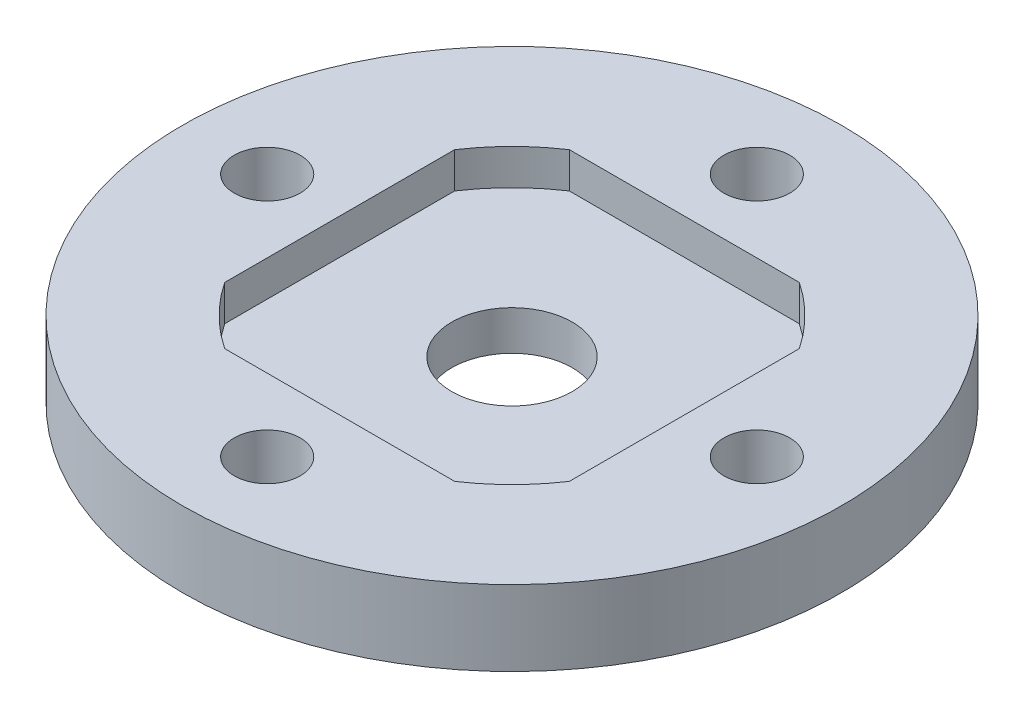
from build123d import *

# Parameters (mm, degrees)
SKETCH_1_R          = 17.5
SKETCH_1_R_2        = 1.75
EXTRUDE_1_DEPTH     = 4
SKETCH_2_R          = 3.2
CUT_EXTRUDE_1_DEPTH = 5
CUT_EXTRUDE_2_DEPTH = 1.9
CHAMFER_1_SIZE      = 1.4


with BuildPart() as part:
    # Эскиз1 → Бобышка-Вытянуть1 (new body)
    with BuildSketch(Plane(origin=(0, 0, 0), x_dir=(1, 0, 0), z_dir=(0, 1, 0))):
        with Locations((0.106470277, -0.341512656)):
            Circle(SKETCH_1_R)
        with Locations((13.106470277, -0.341512656)):
            Circle(SKETCH_1_R_2, mode=Mode.SUBTRACT)
        with Locations((0.106470277, -13.341512656)):
            Circle(SKETCH_1_R_2, mode=Mode.SUBTRACT)
        with Locations((-12.893529723, -0.341512656)):
            Circle(SKETCH_1_R_2, mode=Mode.SUBTRACT)
        with Locations((0.106470277, 12.658487344)):
            Circle(SKETCH_1_R_2, mode=Mode.SUBTRACT)
    extrude(amount=EXTRUDE_1_DEPTH)

    # Эскиз2 → Вырез-Вытянуть1 (cut, through all)
    with BuildSketch(Plane(origin=(0, 4, 0), x_dir=(1, 0, 0), z_dir=(0, 1, 0))):
        with Locations((0.106470277, -0.341512656)):
            Circle(SKETCH_2_R)
    extrude(amount=-CUT_EXTRUDE_1_DEPTH, mode=Mode.SUBTRACT)

    # Эскиз3 → Вырез-Вытянуть2 (cut)
    with BuildSketch(Plane(origin=(0, 4, 0), x_dir=(1, 0, 0), z_dir=(0, 1, 0))):
        with BuildLine():
            Line((6.212000557, 8.808487344), (-5.999060003, 8.808487344))
            ThreePointArc((-5.999060003, 8.808487344), (-7.671704316, 7.436661937), (-9.043529723, 5.764017624))
            Line((-9.043529723, 5.764017624), (-9.043529723, -6.447042936))
            ThreePointArc((-9.043529723, -6.447042936), (-7.671704316, -8.119687249), (-5.999060003, -9.491512656))
            Line((-5.999060003, -9.491512656), (6.212000557, -9.491512656))
            ThreePointArc((6.212000557, -9.491512656), (7.88464487, -8.119687249), (9.256470277, -6.447042936))
            Line((9.256470277, -6.447042936), (9.256470277, 5.764017624))
            ThreePointArc((9.256470277, 5.764017624), (7.88464487, 7.436661937), (6.212000557, 8.808487344))
        make_face()
    extrude(amount=-CUT_EXTRUDE_2_DEPTH, mode=Mode.SUBTRACT)

    # Фаска1
    chamfer_1_edges = [part.edges().sort_by_distance(p)[0] for p in [
        (-14.643529723, 0, 0.341512656),
        (-1.643529723, 0, -12.658487344),
        (11.356470277, 0, 0.341512656),
        (-1.643529723, 0, 13.341512656),
    ]]
    chamfer(chamfer_1_edges, length=CHAMFER_1_SIZE)


solid = part.part
